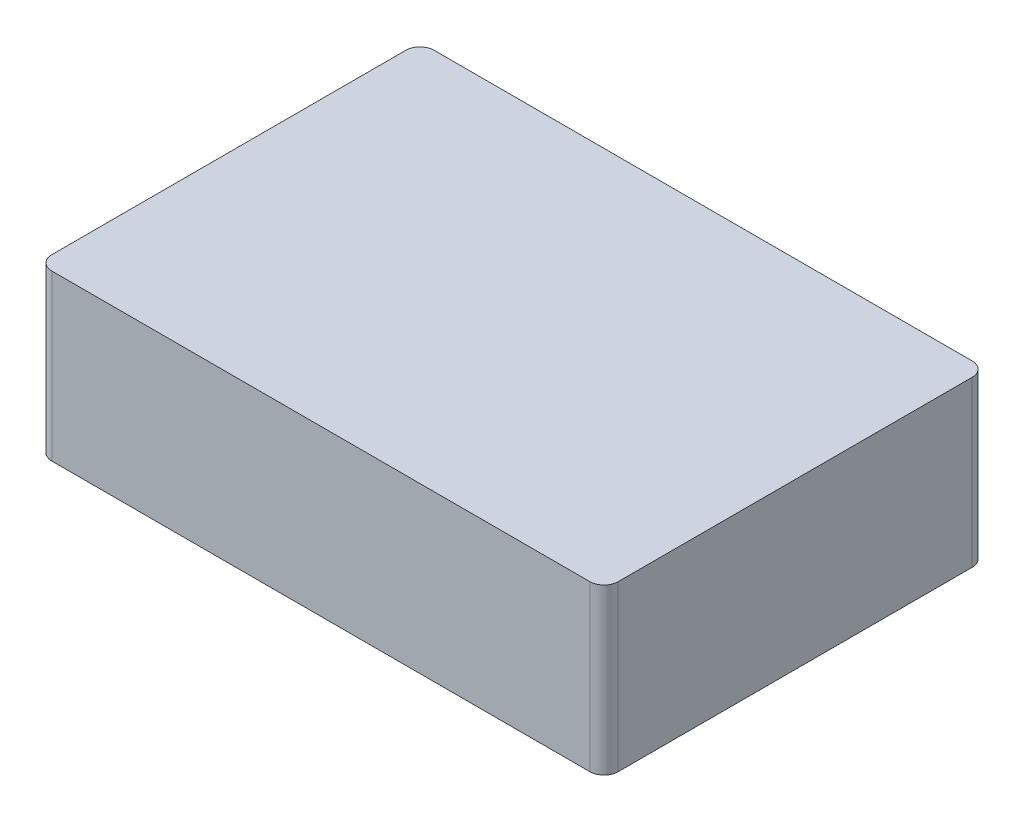
from build123d import *

# Parameters (mm, degrees)
SKETCH1_W           = 80
SKETCH1_H           = 54
BOSS_EXTRUDE2_DEPTH = 23.25
FILLET1_R           = 2


with BuildPart() as part:
    # Sketch1 → Boss-Extrude2 (new body)
    with BuildSketch(Plane(origin=(0, 0, 0), x_dir=(1, 0, 0), z_dir=(0, 1, 0))):
        with Locations((40, 27)):
            Rectangle(SKETCH1_W, SKETCH1_H)
    extrude(amount=BOSS_EXTRUDE2_DEPTH)

    # Fillet1
    fillet1_edges = [part.edges().sort_by_distance(p)[0] for p in [
        (0, 11.625, -54),
        (80, 11.625, -54),
        (80, 11.625, 0),
        (0, 11.625, 0),
    ]]
    fillet(fillet1_edges, radius=FILLET1_R)


solid = part.part
